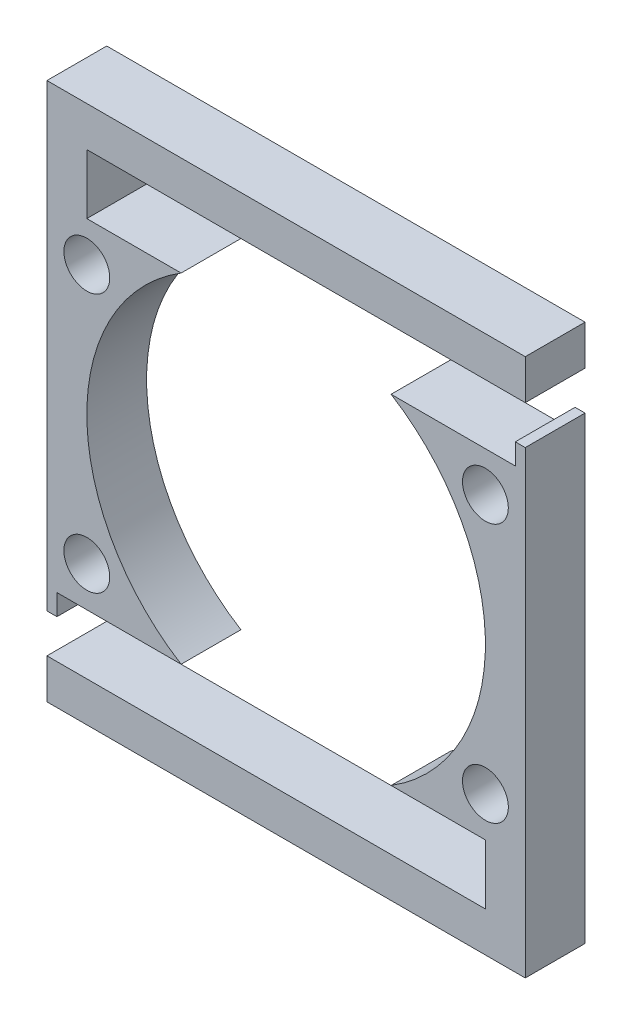
from build123d import *

# Parameters (mm, degrees)
SKETCH2_R             = 1.15
BOSS_EXTRUDE1_DEPTH   = 3
BOSS_EXTRUDE1_2_DEPTH = 3
SKETCH3_W             = 0.5
SKETCH3_H             = 1.05
BOSS_EXTRUDE3_DEPTH   = 3


with BuildPart() as part:
    # Sketch2 → Boss-Extrude1 (new body)
    with BuildSketch(Plane.XY):
        with BuildLine():
            Line((-12, -8.5), (-5.267826876, -8.5))
            ThreePointArc((-5.267826876, -8.5), (-10, 0), (-5.267826876, 8.5))
            Line((-5.267826876, 8.5), (-10, 8.5))
            Line((-10, 8.5), (-10, 11.5))
            Line((-10, 11.5), (12, 11.5))
            Line((12, 11.5), (12, 13.5))
            Line((12, 13.5), (-12, 13.5))
            Line((-12, 13.5), (-12, -8.5))
        make_face()
        with Locations((-10, -6.5)):
            Circle(SKETCH2_R, mode=Mode.SUBTRACT)
        with Locations((-10, 6.5)):
            Circle(SKETCH2_R, mode=Mode.SUBTRACT)
    extrude(amount=BOSS_EXTRUDE1_DEPTH)



with BuildPart() as body_2:
    # Sketch2 → Boss-Extrude1 2 (new body)
    with BuildSketch(Plane.XY):
        with BuildLine():
            Line((-12, -13.5), (12, -13.5))
            Line((12, -13.5), (12, 8.5))
            Line((12, 8.5), (5.267826876, 8.5))
            ThreePointArc((5.267826876, 8.5), (10, 0), (5.267826876, -8.5))
            Line((5.267826876, -8.5), (10, -8.5))
            Line((10, -8.5), (10, -11.5))
            Line((10, -11.5), (-12, -11.5))
            Line((-12, -11.5), (-12, -13.5))
        make_face()
        with Locations((10, 6.5)):
            Circle(SKETCH2_R, mode=Mode.SUBTRACT)
        with Locations((10, -6.5)):
            Circle(SKETCH2_R, mode=Mode.SUBTRACT)
    extrude(amount=BOSS_EXTRUDE1_2_DEPTH)


with BuildPart() as part_1:
    add(part.part)

    add(body_2.part)  # Boss-Extrude3 merges body 2
    # Sketch3 → Boss-Extrude3 (add)
    with BuildSketch(Plane.XY):
        with Locations((11.75, 9.025)):
            Rectangle(SKETCH3_W, SKETCH3_H)
        with Locations((-11.75, -9.025)):
            Rectangle(SKETCH3_W, SKETCH3_H)
    extrude(amount=BOSS_EXTRUDE3_DEPTH)


solid = part_1.part
